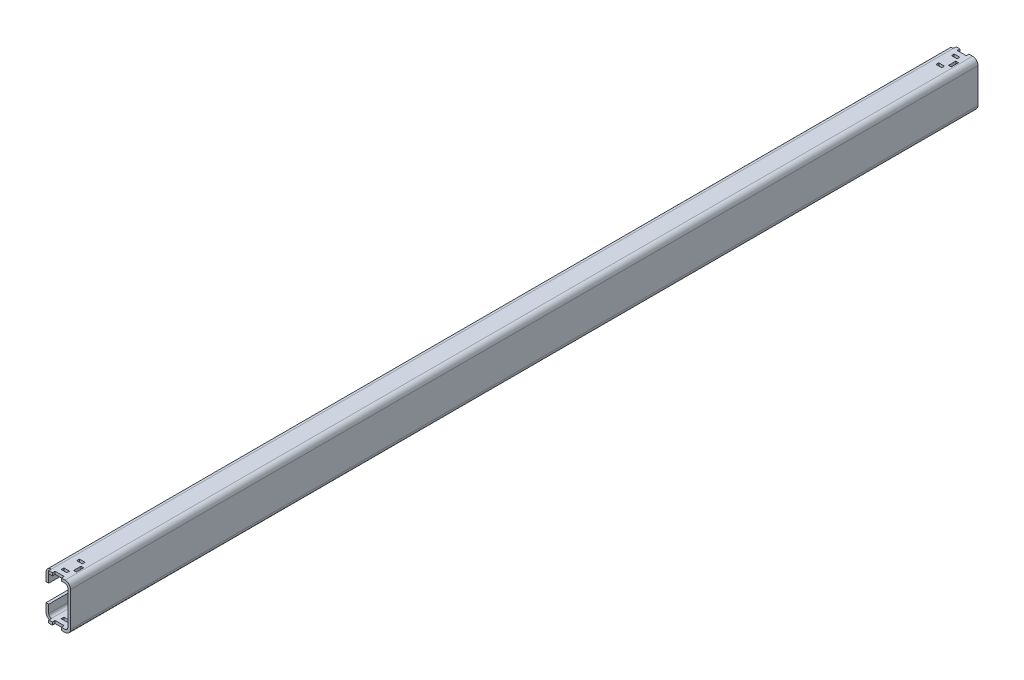
from build123d import *

# Parameters (mm, degrees)
BOSS_EXTRUDE1_DEPTH = 500
FILLET1_R           = 6
FILLET2_R           = 3
SKETCH2_W           = 10
SKETCH2_H           = 3
SKETCH2_W_2         = 6
SKETCH2_W_3         = 6.201832359
SKETCH2_W_4         = 3
SKETCH2_H_2         = 8
CUT_EXTRUDE1_DEPTH  = 50


with BuildPart() as part:
    # Sketch1 → Boss-Extrude1 (new body, symmetric)
    with BuildSketch(Plane.XY):
        Polygon((0, 0), (30, 0), (30, 50), (0, 50), (0, 35), (3, 35), (3, 47), (27, 47), (27, 3), (3, 3), (3, 15), (0, 15), align=None)
    extrude(amount=BOSS_EXTRUDE1_DEPTH, both=True)

    # Fillet1
    fillet1_edges = [part.edges().sort_by_distance(p)[0] for p in [
        (0, 50, 0),
        (30, 50, 0),
        (30, 0, 0),
        (0, 0, 0),
    ]]
    fillet(fillet1_edges, radius=FILLET1_R)

    # Fillet2
    fillet2_edges = [part.edges().sort_by_distance(p)[0] for p in [
        (3, 3, 0),
        (27, 3, 0),
        (27, 47, 0),
        (3, 47, 0),
    ]]
    fillet(fillet2_edges, radius=FILLET2_R)

    # Sketch2 → Cut-Extrude1 (cut)
    with BuildSketch(Plane(origin=(0, 50, 0), x_dir=(1, 0, 0), z_dir=(0, 1, 0))):
        with Locations((15, 498.5)):
            Rectangle(SKETCH2_W, SKETCH2_H)
        with Locations((3, 498.5)):
            Rectangle(SKETCH2_W_2, SKETCH2_H)
        with Locations((3, -498.5)):
            Rectangle(SKETCH2_W_2, SKETCH2_H)
        with Locations((15, -498.5)):
            Rectangle(SKETCH2_W, SKETCH2_H)
        with Locations((14.859499195, 490.5)):
            Rectangle(SKETCH2_W_3, SKETCH2_H)
        with Locations((14.859499195, 473.5)):
            Rectangle(SKETCH2_W_3, SKETCH2_H)
        with Locations((21, 482)):
            Rectangle(SKETCH2_W_4, SKETCH2_H_2)
        with Locations((14.859499195, -473.5)):
            Rectangle(SKETCH2_W_3, SKETCH2_H)
        with Locations((21, -482)):
            Rectangle(SKETCH2_W_4, SKETCH2_H_2)
        with Locations((14.859499195, -490.5)):
            Rectangle(SKETCH2_W_3, SKETCH2_H)
    extrude(amount=-CUT_EXTRUDE1_DEPTH, mode=Mode.SUBTRACT)


solid = part.part
